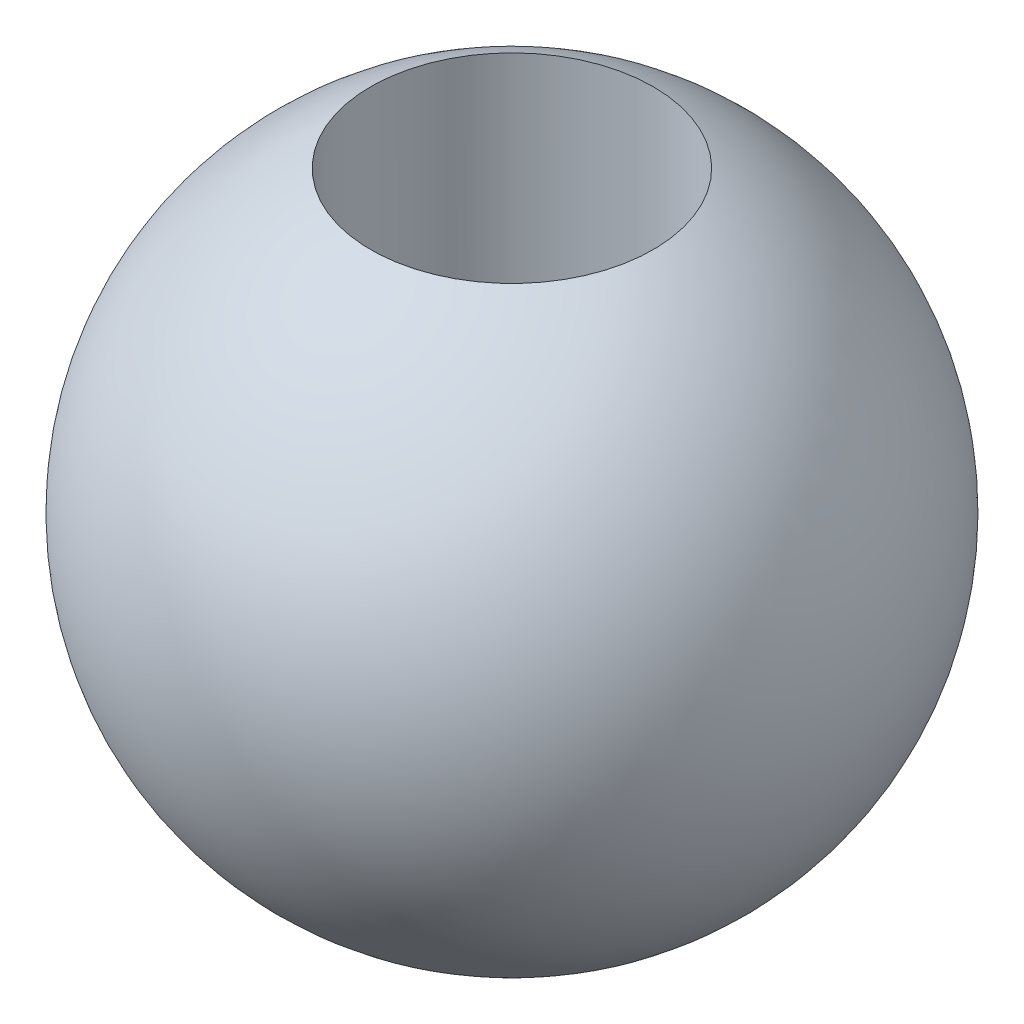
from build123d import *

# Parameters (mm, degrees)
SKETCH2_R               = 3
CUT_EXTRUDE1_DEPTH      = 8
CUT_EXTRUDE1_DEPTH_BACK = 8


with BuildPart() as part:
    # Sketch1 → Revolve1 (revolve)
    with BuildSketch(Plane.XY):
        with BuildLine():
            ThreePointArc((0, 7), (7, 0), (0, -7))
            Line((0, -7), (0, 7))
        make_face()
    revolve(axis=Axis((0, -7, 0), (0, 1, 0)))

    # Sketch2 → Cut-Extrude1 (cut, two sides)
    with BuildSketch(Plane(origin=(0, 0, 0), x_dir=(1, 0, 0), z_dir=(0, 1, 0))) as cut_extrude1_sk:
        Circle(SKETCH2_R)
    extrude(amount=CUT_EXTRUDE1_DEPTH, mode=Mode.SUBTRACT)
    extrude(cut_extrude1_sk.sketch, amount=-CUT_EXTRUDE1_DEPTH_BACK, mode=Mode.SUBTRACT)


solid = part.part
